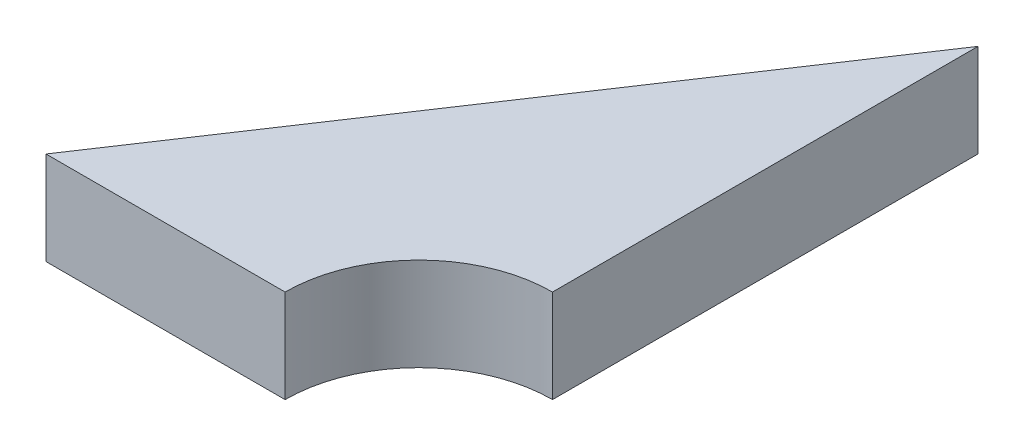
from build123d import *

# Parameters (mm, degrees)
BOSS_EXTRUDE1_DEPTH = 5


with BuildPart() as part:
    # Sketch1 → Boss-Extrude1 (new body)
    with BuildSketch(Plane(origin=(0, 0, 0), x_dir=(1, 0, 0), z_dir=(0, 1, 0))):
        with BuildLine():
            Line((-10.196977124, -4.156862984), (2.629276684, -4.156862984))
            ThreePointArc((2.629276684, -4.156862984), (4.730418297, 0.915741594), (9.803022876, 3.016883207))
            Line((9.803022876, 3.016883207), (9.803022876, 25.843137016))
            Line((9.803022876, 25.843137016), (-10.196977124, -4.156862984))
        make_face()
    extrude(amount=BOSS_EXTRUDE1_DEPTH)


solid = part.part
